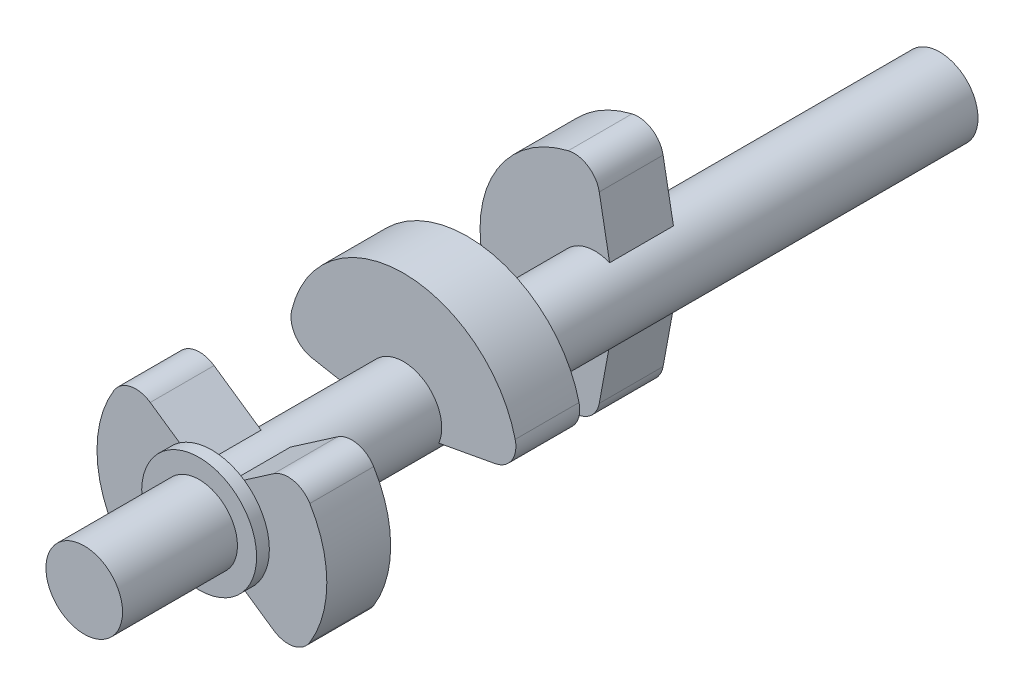
from build123d import *

# Parameters (mm, degrees)
SKETCH_2_R       = 1.5
SHAFT_DEPTH      = 33.5
EXCENTRIC1_DEPTH = 2.5
EXTRUDE_3_DEPTH  = 2.5
EXTRUDE_4_DEPTH  = 2.5
FILLET_1_R       = 1
SKETCH_7_R       = 2.25
EXTRUDE_5_DEPTH  = 0.5


with BuildPart() as part:
    # Эскиз2 → shaft (new body)
    with BuildSketch(Plane.XY):
        Circle(SKETCH_2_R)
    extrude(amount=SHAFT_DEPTH)

    # Эскиз3 → excentric1 (add)
    with BuildSketch(Plane(origin=(0, 0, 11), x_dir=(-1, 0, 0), z_dir=(0, 0, -1))):
        with BuildLine():
            ThreePointArc((4.5, 0), (3.181980515, 3.181980515), (0, 4.5))
            Line((0, 4.5), (-0.574025149, 1.385819299))
            ThreePointArc((-0.574025149, 1.385819299), (0.83335535, 1.247204418), (1.5, 0))
            ThreePointArc((1.5, 0), (0.83335535, -1.247204418), (-0.574025149, -1.385819299))
            Line((-0.574025149, -1.385819299), (0, -4.5))
            ThreePointArc((0, -4.5), (3.181980515, -3.181980515), (4.5, 0))
        make_face()
    extrude(amount=-EXCENTRIC1_DEPTH)

    # excentric2sketch → Бобышка-Вытянуть3 (add)
    with BuildSketch(Plane(origin=(0, 0, 18.5), x_dir=(-1, 0, 0), z_dir=(0, 0, -1))):
        with BuildLine():
            ThreePointArc((4.5, 0), (0, 4.5), (-4.5, 0))
            Line((-4.5, 0), (-1.385819299, -0.574025149))
            ThreePointArc((-1.385819299, -0.574025149), (-0.292635483, 1.471177921), (1.5, 0))
            ThreePointArc((1.5, 0), (1.471177921, -0.292635483), (1.385819299, -0.574025149))
            Line((1.385819299, -0.574025149), (4.5, 0))
        make_face()
    extrude(amount=-EXTRUDE_3_DEPTH)

    # excentric3sketch → Бобышка-Вытянуть4 (add)
    with BuildSketch(Plane(origin=(0, 0, 26), x_dir=(-1, 0, 0), z_dir=(0, 0, -1))):
        with BuildLine():
            Line((-0.574025149, 1.385819299), (-3.181980515, 3.181980515))
            ThreePointArc((-3.181980515, 3.181980515), (-4.5, 0), (-3.181980515, -3.181980515))
            Line((-3.181980515, -3.181980515), (-0.574025149, -1.385819299))
            ThreePointArc((-0.574025149, -1.385819299), (-1.5, 0), (-0.574025149, 1.385819299))
        make_face()
        with BuildLine():
            ThreePointArc((4.5, 0), (4.157457896, 1.722075446), (3.181980515, 3.181980515))
            Line((3.181980515, 3.181980515), (0.574025149, 1.385819299))
            ThreePointArc((0.574025149, 1.385819299), (1.247204418, 0.83335535), (1.5, 0))
            ThreePointArc((1.5, 0), (1.247204418, -0.83335535), (0.574025149, -1.385819299))
            Line((0.574025149, -1.385819299), (3.181980515, -3.181980515))
            ThreePointArc((3.181980515, -3.181980515), (4.157457896, -1.722075446), (4.5, 0))
        make_face()
    extrude(amount=-EXTRUDE_4_DEPTH)

    # Скругление1
    fillet_1_edges = [part.edges().sort_by_distance(p)[0] for p in [
        (4.5, 0, 19.75),
        (-4.5, 0, 19.75),
        (3.181980515, -3.181980515, 27.25),
        (3.181980515, 3.181980515, 27.25),
        (-3.181980515, 3.181980515, 27.25),
        (-3.181980515, -3.181980515, 27.25),
        (0, 4.5, 12.25),
        (0, -4.5, 12.25),
    ]]
    fillet(fillet_1_edges, radius=FILLET_1_R)

    # Эскиз7 → Бобышка-Вытянуть5 (add)
    with BuildSketch(Plane.XY.offset(28.5)):
        Circle(SKETCH_7_R)
    extrude(amount=EXTRUDE_5_DEPTH)


solid = part.part
